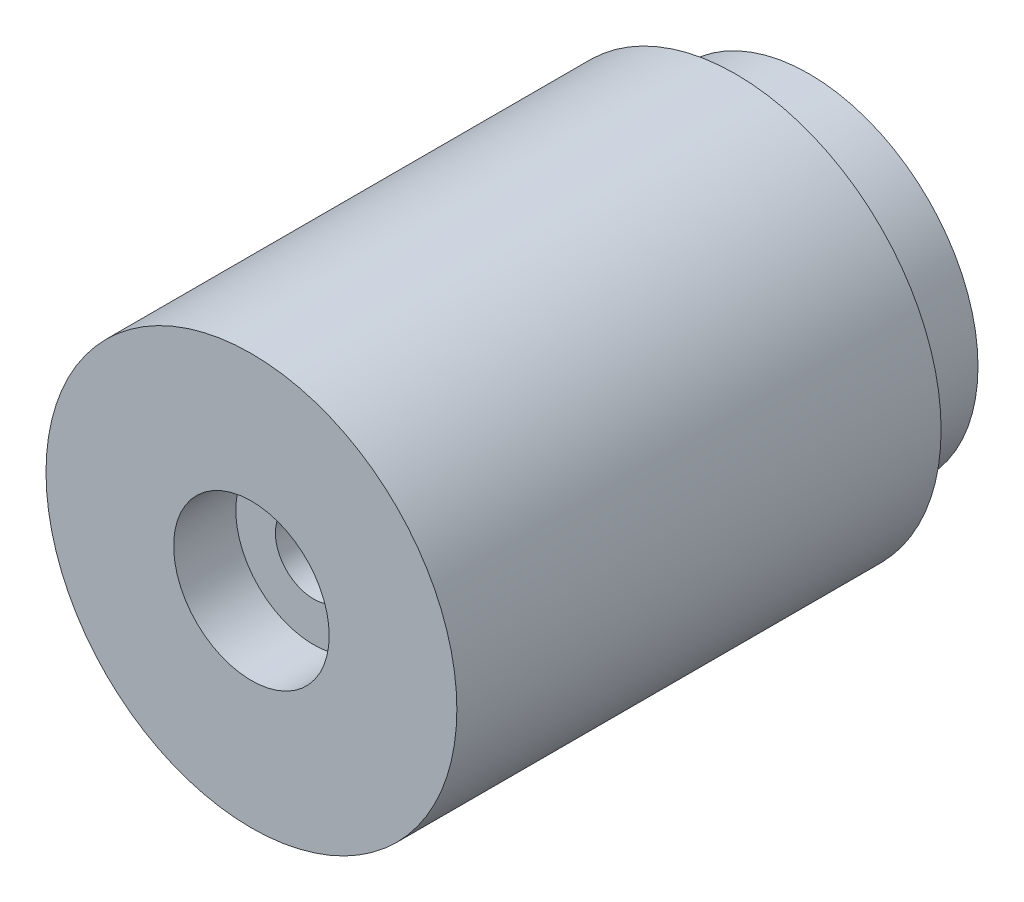
from build123d import *

# Parameters (mm, degrees)
CROQUIS1_R              = 21
SALIENTE_EXTRUIR1_DEPTH = 49.5
CROQUIS3_R              = 3.9
CORTAR_EXTRUIR1_DEPTH   = 50.5
CROQUIS4_R              = 17.272
SALIENTE_EXTRUIR2_DEPTH = 7.5
CROQUIS5_R              = 3.9
CORTAR_EXTRUIR2_DEPTH   = 7.5
CROQUIS6_R              = 7.95
CORTAR_EXTRUIR3_DEPTH   = 6.35
CROQUIS7_R              = 7.95
CORTAR_EXTRUIR4_DEPTH   = 6.35


with BuildPart() as part:
    # Croquis1 → Saliente-Extruir1 (new body)
    with BuildSketch(Plane.XY):
        Circle(CROQUIS1_R)
    extrude(amount=SALIENTE_EXTRUIR1_DEPTH)

    # Croquis3 → Cortar-Extruir1 (cut, through all)
    with BuildSketch(Plane(origin=(0, 0, 0), x_dir=(-1, 0, 0), z_dir=(0, 0, -1))):
        Circle(CROQUIS3_R)
    extrude(amount=-CORTAR_EXTRUIR1_DEPTH, mode=Mode.SUBTRACT)

    # Croquis4 → Saliente-Extruir2 (add)
    with BuildSketch(Plane(origin=(0, 0, 0), x_dir=(-1, 0, 0), z_dir=(0, 0, -1))):
        Circle(CROQUIS4_R)
    extrude(amount=SALIENTE_EXTRUIR2_DEPTH)

    # Croquis5 → Cortar-Extruir2 (cut)
    with BuildSketch(Plane(origin=(0, 0, -7.5), x_dir=(-1, 0, 0), z_dir=(0, 0, -1))):
        Circle(CROQUIS5_R)
    extrude(amount=-CORTAR_EXTRUIR2_DEPTH, mode=Mode.SUBTRACT)

    # Croquis6 → Cortar-Extruir3 (cut)
    with BuildSketch(Plane(origin=(0, 0, -7.5), x_dir=(-1, 0, 0), z_dir=(0, 0, -1))):
        Circle(CROQUIS6_R)
    extrude(amount=-CORTAR_EXTRUIR3_DEPTH, mode=Mode.SUBTRACT)

    # Croquis7 → Cortar-Extruir4 (cut)
    with BuildSketch(Plane.XY.offset(49.5)):
        Circle(CROQUIS7_R)
    extrude(amount=-CORTAR_EXTRUIR4_DEPTH, mode=Mode.SUBTRACT)


solid = part.part
